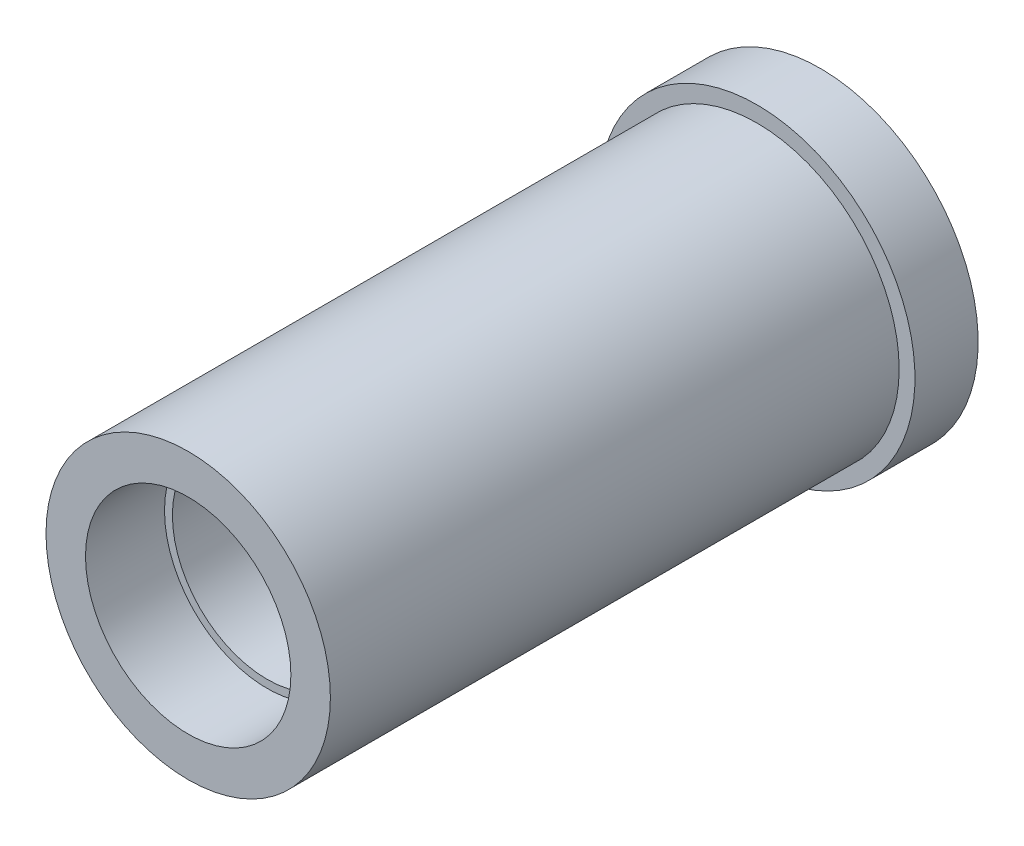
from build123d import *

# Parameters (mm, degrees)
SKETCH_1_R          = 9
SKETCH_1_R_2        = 6
EXTRUDE_1_DEPTH     = 40
SKETCH_2_R          = 6.5
CUT_EXTRUDE_1_DEPTH = 5
SKETCH_3_R          = 6.5
CUT_EXTRUDE_2_DEPTH = 5
SKETCH_4_R          = 10
SKETCH_4_R_2        = 9
EXTRUDE_2_DEPTH     = 4


with BuildPart() as part:
    # 草图1 → 凸台-拉伸1 (new body)
    with BuildSketch(Plane.XY):
        Circle(SKETCH_1_R)
        Circle(SKETCH_1_R_2, mode=Mode.SUBTRACT)
    extrude(amount=EXTRUDE_1_DEPTH)

    # 草图2 → 切除-拉伸1 (cut)
    with BuildSketch(Plane.XY.offset(40)):
        Circle(SKETCH_2_R)
    extrude(amount=-CUT_EXTRUDE_1_DEPTH, mode=Mode.SUBTRACT)

    # 草图3 → 切除-拉伸2 (cut)
    with BuildSketch(Plane(origin=(0, 0, 0), x_dir=(-1, 0, 0), z_dir=(0, 0, -1))):
        Circle(SKETCH_3_R)
    extrude(amount=-CUT_EXTRUDE_2_DEPTH, mode=Mode.SUBTRACT)

    # 草图4 → 凸台-拉伸2 (add)
    with BuildSketch(Plane(origin=(0, 0, 0), x_dir=(-1, 0, 0), z_dir=(0, 0, -1))):
        Circle(SKETCH_4_R)
        Circle(SKETCH_4_R_2, mode=Mode.SUBTRACT)
    extrude(amount=-EXTRUDE_2_DEPTH)


solid = part.part
